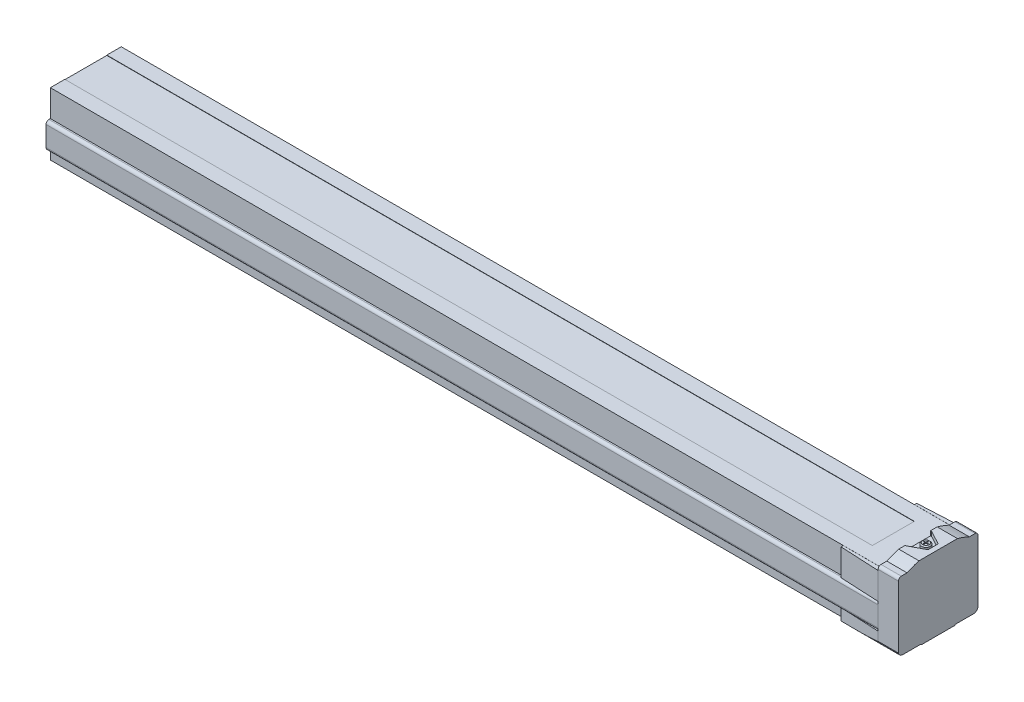
from build123d import *

# Parameters (mm, degrees)
BOSS_EXTRUDE1_DEPTH          = 930
SKETCH2_W                    = 204.786284779
SKETCH2_H                    = 168.647528641
CUT_EXTRUDE1_DEPTH           = 909.5
SKETCH3_W                    = 400
SKETCH3_H                    = 200
CUT_EXTRUDE2_DEPTH           = 930
BOSS_EXTRUDE2_DEPTH          = 127.35
CUT_REVOLVE1_ANGLE           = 75
CUT_REVOLVE1_OTHER_WAY_ANGLE = 75
CUT_EXTRUDE4_DEPTH           = 20
CUT_EXTRUDE5_DEPTH           = 1
CUT_EXTRUDE6_DEPTH           = 20
CUT_EXTRUDE6_DEPTH_BACK      = 20
CUT_EXTRUDE7_DEPTH           = 6
BOSS_EXTRUDE8_DEPTH          = 21.2
CUT_EXTRUDE9_DEPTH           = 30
CUT_EXTRUDE9_DEPTH_BACK      = 30
CUT_EXTRUDE10_DEPTH          = 2
CUT_EXTRUDE10_DEPTH_BACK     = 2
SKETCH14_R                   = 3.25
BOSS_EXTRUDE3_DEPTH          = 20
SKETCH15_R                   = 3.25
BOSS_EXTRUDE4_DEPTH          = 20
BOSS_EXTRUDE5_DEPTH          = 8.56
SKETCH17_W                   = 235.37802201
SKETCH17_H                   = 195.027503951
CUT_EXTRUDE14_DEPTH          = 40
BOSS_EXTRUDE6_DEPTH          = 18.5
BOSS_EXTRUDE7_DEPTH          = 8.56
CUT_EXTRUDE17_START          = -50
SKETCH20_W                   = 235.37802201
SKETCH20_H                   = 195.027503951
CUT_EXTRUDE17_DEPTH          = 50
CUT_EXTRUDE18_DEPTH          = 3
SKETCH23_W                   = 742
SKETCH23_H                   = 29
CUT_EXTRUDE19_DEPTH          = 0.2
CUT_EXTRUDE20_DEPTH          = 25
CUT_EXTRUDE20_DEPTH_BACK     = 25
CUT_EXTRUDE21_DEPTH          = 16
CUT_EXTRUDE22_DEPTH          = 16
CUT_EXTRUDE23_DEPTH          = 34
CUT_EXTRUDE24_DEPTH          = 34
CUT_EXTRUDE25_DEPTH          = 16
CUT_EXTRUDE26_DEPTH          = 16
CUT_EXTRUDE27_DEPTH          = 12.5
CUT_EXTRUDE28_DEPTH          = 12.5
CUT_EXTRUDE_1_DEPTH          = 341
CUT_EXTRUDE_1_DEPTH_BACK     = 341
SKETCH_2_W                   = 173.292997311
SKETCH_2_H                   = 116.860407409


with BuildPart() as part:
    # Sketch1 → Boss-Extrude1 (new body)
    with BuildSketch(Plane(origin=(0, 0, 0), x_dir=(0, 0, -1), z_dir=(1, 0, 0))):
        with BuildLine():
            Line((-28.5, 46), (-28.5, 2.971392601))
            Line((-28.5, 2.971392601), (-27.5, 2.971392601))
            Line((-27.5, 2.971392601), (-27.328427125, 2.5))
            ThreePointArc((-27.328427125, 2.5), (-26.232050808, 1.050510257), (-24.5, 0.5))
            Line((-24.5, 0.5), (-12, 0.5))
            Line((-12, 0.5), (-11.5, 0))
            Line((-11.5, 0), (11.5, 0))
            Line((11.5, 0), (12, 0.5))
            Line((12, 0.5), (24.5, 0.5))
            ThreePointArc((24.5, 0.5), (26.232050808, 1.050510257), (27.328427125, 2.5))
            Line((27.328427125, 2.5), (27.5, 2.971392601))
            Line((27.5, 2.971392601), (28.5, 2.971392601))
            Line((28.5, 2.971392601), (28.5, 46))
            Line((28.5, 46), (27.5, 46))
            ThreePointArc((27.5, 46), (26.914213562, 47.414213562), (25.5, 48))
            Line((25.5, 48), (21.524012172, 48))
            ThreePointArc((21.524012172, 48), (17.477101448, 49.71603425), (13.295111884, 51.07))
            Line((13.295111884, 51.07), (-13.295111884, 51.07))
            ThreePointArc((-13.295111884, 51.07), (-17.477101448, 49.71603425), (-21.524012172, 48))
            Line((-21.524012172, 48), (-25.5, 48))
            ThreePointArc((-25.5, 48), (-26.914213562, 47.414213562), (-27.5, 46))
            Line((-27.5, 46), (-28.5, 46))
        make_face()
    extrude(amount=BOSS_EXTRUDE1_DEPTH)

    # Sketch2 → Cut-Extrude1 (cut)
    with BuildSketch(Plane(origin=(916, 0, 0), x_dir=(0, 0, -1), z_dir=(1, 0, 0))):
        with Locations((9.532349098, 15.424002622)):
            Rectangle(SKETCH2_W, SKETCH2_H)
        with BuildLine():
            Line((-27.5, 24.8), (-27.5, 11))
            ThreePointArc((-27.5, 11), (-26.914213562, 9.585786438), (-25.5, 9))
            Line((-25.5, 9), (-24.5, 9))
            Line((-24.5, 9), (-24.5, 2))
            Line((-24.5, 2), (-22.5, 0))
            Line((-22.5, 0), (22.5, 0))
            Line((22.5, 0), (24.5, 2))
            Line((24.5, 2), (24.5, 9))
            Line((24.5, 9), (25.5, 9))
            ThreePointArc((25.5, 9), (26.914213562, 9.585786438), (27.5, 11))
            Line((27.5, 11), (27.5, 24.8))
            ThreePointArc((27.5, 24.8), (26.914213562, 26.214213562), (25.5, 26.8))
            Line((25.5, 26.8), (24.5, 26.8))
            Line((24.5, 26.8), (24.5, 45.3))
            Line((24.5, 45.3), (-24.5, 45.3))
            Line((-24.5, 45.3), (-24.5, 26.8))
            Line((-24.5, 26.8), (-25.5, 26.8))
            ThreePointArc((-25.5, 26.8), (-26.914213562, 26.214213562), (-27.5, 24.8))
        make_face(mode=Mode.SUBTRACT)
    extrude(amount=-CUT_EXTRUDE1_DEPTH, mode=Mode.SUBTRACT)

    # Sketch3 → Cut-Extrude2 (cut)
    with BuildSketch(Plane(origin=(0, 0, 0), x_dir=(0, 0, -1), z_dir=(1, 0, 0))):
        Rectangle(SKETCH3_W, SKETCH3_H)
        with BuildLine():
            Line((-27.5, 46), (-27.5, 2.971392601))
            Line((-27.5, 2.971392601), (-27.328427125, 2.5))
            ThreePointArc((-27.328427125, 2.5), (-26.232050808, 1.050510257), (-24.5, 0.5))
            Line((-24.5, 0.5), (-12, 0.5))
            Line((-12, 0.5), (-11.5, 0))
            Line((-11.5, 0), (11.5, 0))
            Line((11.5, 0), (12, 0.5))
            Line((12, 0.5), (24.5, 0.5))
            ThreePointArc((24.5, 0.5), (26.232050808, 1.050510257), (27.328427125, 2.5))
            Line((27.328427125, 2.5), (27.5, 2.971392601))
            Line((27.5, 2.971392601), (27.5, 46))
            ThreePointArc((27.5, 46), (26.914213562, 47.414213562), (25.5, 48))
            Line((25.5, 48), (21.524012172, 48))
            ThreePointArc((21.524012172, 48), (17.477101448, 49.71603425), (13.295111884, 51.07))
            Line((13.295111884, 51.07), (-13.295111884, 51.07))
            ThreePointArc((-13.295111884, 51.07), (-17.477101448, 49.71603425), (-21.524012172, 48))
            Line((-21.524012172, 48), (-25.5, 48))
            ThreePointArc((-25.5, 48), (-26.914213562, 47.414213562), (-27.5, 46))
        make_face(mode=Mode.SUBTRACT)
    extrude(amount=CUT_EXTRUDE2_DEPTH, mode=Mode.SUBTRACT)

    # Sketch4 → Boss-Extrude2 (add)
    with BuildSketch(Plane(origin=(0, 0, 0), x_dir=(0, 0, -1), z_dir=(1, 0, 0))):
        with BuildLine():
            Line((-24.5, 30), (24.5, 30))
            Line((24.5, 30), (24.5, 45.3))
            Line((24.5, 45.3), (24.45, 45.3))
            Line((24.45, 45.3), (24.5, 45.35))
            Line((24.5, 45.35), (24.5, 48))
            Line((24.5, 48), (24, 48))
            Line((24, 48), (22.285663539, 52.710100717))
            ThreePointArc((22.285663539, 52.710100717), (20.455082617, 55.095760221), (17.587200435, 56))
            Line((17.587200435, 56), (-17.084187431, 56))
            ThreePointArc((-17.084187431, 56), (-19.770685472, 55.216957229), (-21.615726366, 53.113091309))
            Line((-21.615726366, 53.113091309), (-24, 48))
            Line((-24, 48), (-24.5, 48))
            Line((-24.5, 48), (-24.5, 45.35))
            Line((-24.5, 45.35), (-24.45, 45.3))
            Line((-24.45, 45.3), (-24.5, 45.3))
            Line((-24.5, 45.3), (-24.5, 30))
        make_face()
    extrude(amount=BOSS_EXTRUDE2_DEPTH)

    # Sketch5 → Cut-Revolve1 (revolve, cut)
    with BuildSketch(Plane.XY):
        with BuildLine():
            Line((97.35, 71.971261171), (150, 71.971261171))
            Line((150, 71.971261171), (150, 45.3))
            Line((150, 45.3), (127.35, 45.3))
            Line((127.35, 45.3), (127.35, 45.79))
            ThreePointArc((127.35, 45.79), (127.234272347, 46.460460828), (126.900482278, 47.053330799))
            Line((126.900482278, 47.053330799), (120.296542673, 55.158326997))
            ThreePointArc((120.296542673, 55.158326997), (118.566072869, 56.516172881), (116.420336979, 57))
            Line((116.420336979, 57), (97.35, 57))
            Line((97.35, 57), (97.35, 71.971261171))
        make_face()
    revolve(axis=Axis((97.35, 57, 0), (0, -1, 0)), revolution_arc=CUT_REVOLVE1_ANGLE, mode=Mode.SUBTRACT)

    # Sketch5 → Cut-Revolve1 other way (revolve, cut)
    with BuildSketch(Plane.XY):
        with BuildLine():
            Line((97.35, 71.971261171), (150, 71.971261171))
            Line((150, 71.971261171), (150, 45.3))
            Line((150, 45.3), (127.35, 45.3))
            Line((127.35, 45.3), (127.35, 45.79))
            ThreePointArc((127.35, 45.79), (127.234272347, 46.460460828), (126.900482278, 47.053330799))
            Line((126.900482278, 47.053330799), (120.296542673, 55.158326997))
            ThreePointArc((120.296542673, 55.158326997), (118.566072869, 56.516172881), (116.420336979, 57))
            Line((116.420336979, 57), (97.35, 57))
            Line((97.35, 57), (97.35, 71.971261171))
        make_face()
    revolve(axis=Axis((97.35, 57, 0), (0, 1, 0)), revolution_arc=CUT_REVOLVE1_OTHER_WAY_ANGLE, mode=Mode.SUBTRACT)

    # Sketch6 → Cut-Extrude4 (cut)
    with BuildSketch(Plane(origin=(0, 48, 0), x_dir=(-1, 0, 0), z_dir=(0, 1, 0))):
        Polygon((-916, 8.7), (-916.72022238, 8.7), (-926.5, 3.5), (-926.5, -3.5), (-916.72022238, -8.7), (-916, -8.7), align=None)
    extrude(amount=CUT_EXTRUDE4_DEPTH, mode=Mode.SUBTRACT)

    # Sketch7 → Revolve1 (revolve)
    with BuildSketch(Plane.XY):
        Polygon((921.5, 48), (918.5, 48), (918.5, 50.292893219), (919.207106781, 51), (921.5, 51), align=None)
    revolve(axis=Axis((921.5, 51, 0), (0, -1, 0)))

    # Sketch8 → Cut-Extrude5 (cut)
    with BuildSketch(Plane(origin=(0, 51, 0), x_dir=(-1, 0, 0), z_dir=(0, 1, 0))):
        with BuildLine():
            Line((-923.071623365, -0.3), (-921.8, -0.3))
            Line((-921.8, -0.3), (-921.8, -1.571623365))
            ThreePointArc((-921.8, -1.571623365), (-921.5, -1.6), (-921.2, -1.571623365))
            Line((-921.2, -1.571623365), (-921.2, -0.3))
            Line((-921.2, -0.3), (-919.928376635, -0.3))
            ThreePointArc((-919.928376635, -0.3), (-919.9, 0), (-919.928376635, 0.3))
            Line((-919.928376635, 0.3), (-921.2, 0.3))
            Line((-921.2, 0.3), (-921.2, 1.571623365))
            ThreePointArc((-921.2, 1.571623365), (-921.5, 1.6), (-921.8, 1.571623365))
            Line((-921.8, 1.571623365), (-921.8, 0.3))
            Line((-921.8, 0.3), (-923.071623365, 0.3))
            ThreePointArc((-923.071623365, 0.3), (-923.1, 0), (-923.071623365, -0.3))
        make_face()
    extrude(amount=-CUT_EXTRUDE5_DEPTH, mode=Mode.SUBTRACT)

    # Sketch9 → Cut-Extrude6 (cut, two sides: drawn at the far end of the back side and taken through both)
    with BuildSketch(Plane.XY.offset(-CUT_EXTRUDE6_DEPTH_BACK)):
        Polygon((-50, 0.5), (-50, 0), (79, 0), (78.5, 0.5), align=None)
    extrude(amount=CUT_EXTRUDE6_DEPTH + CUT_EXTRUDE6_DEPTH_BACK, mode=Mode.SUBTRACT)

    # Sketch10 → Cut-Extrude7 (cut)
    with BuildSketch(Plane(origin=(0, 0, 0), x_dir=(-1, 0, 0), z_dir=(0, 1, 0))):
        with BuildLine():
            Line((-625.5, 2), (-627.5, 2))
            ThreePointArc((-627.5, 2), (-629.5, 0), (-627.5, -2))
            Line((-627.5, -2), (-625.5, -2))
            ThreePointArc((-625.5, -2), (-623.5, 0), (-625.5, 2))
        make_face()
    extrude(amount=CUT_EXTRUDE7_DEPTH, mode=Mode.SUBTRACT)

    # Sketch11 → Boss-Extrude8 (add)
    with BuildSketch(Plane(origin=(0, 26.8, 0), x_dir=(-1, 0, 0), z_dir=(0, 1, 0))):
        Polygon((0, 27.5), (-6, 27.5), (-34, 26.1), (-34, -26.1), (-6, -27.5), (0, -27.5), align=None)
    extrude(amount=BOSS_EXTRUDE8_DEPTH)

    # Sketch12 → Cut-Extrude9 (cut, two sides: drawn at the far end of the back side and taken through both)
    with BuildSketch(Plane.XY.offset(-CUT_EXTRUDE9_DEPTH_BACK)):
        with BuildLine():
            Line((-20, -15), (15, -15))
            Line((15, -15), (15, 0))
            Line((15, 0), (5.587775501, 0))
            ThreePointArc((5.587775501, 0), (2.209824463, 1.313613316), (0.60680201, 4.564221286))
            Line((0.60680201, 4.564221286), (0, 11.5))
            Line((0, 11.5), (0, 40.45))
            Line((0, 40.45), (2.189670922, 52.868240888))
            ThreePointArc((2.189670922, 52.868240888), (3.899771638, 55.830222216), (7.113709687, 57))
            Line((7.113709687, 57), (15, 57))
            Line((15, 57), (15, 60))
            Line((15, 60), (-20, 60))
            Line((-20, 60), (-20, -15))
        make_face()
    extrude(amount=CUT_EXTRUDE9_DEPTH + CUT_EXTRUDE9_DEPTH_BACK, mode=Mode.SUBTRACT)

    # Sketch13 → Cut-Extrude10 (cut, two sides: drawn at the far end of the back side and taken through both)
    with BuildSketch(Plane(origin=(0, 0, 0), x_dir=(0, 0, -1), z_dir=(1, 0, 0)).offset(-CUT_EXTRUDE10_DEPTH_BACK)):
        with BuildLine():
            Line((-10, 46.95), (-10, 42.95))
            ThreePointArc((-10, 42.95), (-8.535533906, 39.414466094), (-5, 37.95))
            Line((-5, 37.95), (5, 37.95))
            ThreePointArc((5, 37.95), (8.535533906, 39.414466094), (10, 42.95))
            Line((10, 42.95), (10, 46.95))
            ThreePointArc((10, 46.95), (9.707106781, 47.657106781), (9, 47.95))
            Line((9, 47.95), (-9, 47.95))
            ThreePointArc((-9, 47.95), (-9.707106781, 47.657106781), (-10, 46.95))
        make_face()
    extrude(amount=CUT_EXTRUDE10_DEPTH + CUT_EXTRUDE10_DEPTH_BACK, mode=Mode.SUBTRACT)

    # Sketch14 → Boss-Extrude3 (add)
    with BuildSketch(Plane(origin=(2, 0, 0), x_dir=(0, 0, -1), z_dir=(1, 0, 0))):
        with Locations((-3.5, 43.7)):
            Circle(SKETCH14_R)
    extrude(amount=-BOSS_EXTRUDE3_DEPTH)

    # Sketch15 → Boss-Extrude4 (add)
    with BuildSketch(Plane(origin=(2, 0, 0), x_dir=(0, 0, -1), z_dir=(1, 0, 0))):
        with Locations((3.5, 43.7)):
            Circle(SKETCH15_R)
    extrude(amount=-BOSS_EXTRUDE4_DEPTH)

    # Sketch16 → Boss-Extrude5 (add)
    with BuildSketch(Plane(origin=(0, 9, 0), x_dir=(-1, 0, 0), z_dir=(0, 1, 0))):
        Polygon((0, 27.5), (-6, 27.5), (-34, 26.1), (-34, -26.1), (-6, -27.5), (0, -27.5), align=None)
    extrude(amount=-BOSS_EXTRUDE5_DEPTH)

    # Sketch17 → Cut-Extrude14 (cut)
    with BuildSketch(Plane(origin=(0, 0, 0), x_dir=(0, 0, -1), z_dir=(1, 0, 0))):
        with Locations((8.296344577, 18.152881027)):
            Rectangle(SKETCH17_W, SKETCH17_H)
        with BuildLine():
            Line((-27.5, 46), (-27.5, 2.971392601))
            Line((-27.5, 2.971392601), (-27.328427125, 2.5))
            ThreePointArc((-27.328427125, 2.5), (-26.232050808, 1.050510257), (-24.5, 0.5))
            Line((-24.5, 0.5), (24.5, 0.5))
            ThreePointArc((24.5, 0.5), (26.232050808, 1.050510257), (27.328427125, 2.5))
            Line((27.328427125, 2.5), (27.5, 2.971392601))
            Line((27.5, 2.971392601), (27.5, 46))
            ThreePointArc((27.5, 46), (26.914213562, 47.414213562), (25.5, 48))
            Line((25.5, 48), (24, 48))
            Line((24, 48), (24, 65))
            Line((24, 65), (-24, 65))
            Line((-24, 65), (-24, 48))
            Line((-24, 48), (-25.5, 48))
            ThreePointArc((-25.5, 48), (-26.914213562, 47.414213562), (-27.5, 46))
        make_face(mode=Mode.SUBTRACT)
    extrude(amount=CUT_EXTRUDE14_DEPTH, mode=Mode.SUBTRACT)

    # Sketch18 → Boss-Extrude6 (add)
    with BuildSketch(Plane(origin=(0, 26.8, 0), x_dir=(-1, 0, 0), z_dir=(0, 1, 0))):
        Polygon((-889, 26.1), (-917, 27.5), (-923, 27.5), (-923, -27.5), (-917, -27.5), (-889, -26.1), align=None)
    extrude(amount=BOSS_EXTRUDE6_DEPTH)

    # Sketch19 → Boss-Extrude7 (add)
    with BuildSketch(Plane(origin=(0, 9, 0), x_dir=(-1, 0, 0), z_dir=(0, 1, 0))):
        Polygon((-889, 26.1), (-917, 27.5), (-930, 27.5), (-930, -27.5), (-917, -27.5), (-889, -26.1), align=None)
    extrude(amount=-BOSS_EXTRUDE7_DEPTH)

    # Sketch20 → Cut-Extrude17 (cut)
    with BuildSketch(Plane(origin=(930, 0, 0), x_dir=(0, 0, -1), z_dir=(1, 0, 0)).offset(CUT_EXTRUDE17_START)):
        with Locations((8.296344577, 18.152881027)):
            Rectangle(SKETCH20_W, SKETCH20_H)
        with BuildLine():
            Line((-27.5, 46), (-27.5, 2.971392601))
            Line((-27.5, 2.971392601), (-27.328427125, 2.5))
            ThreePointArc((-27.328427125, 2.5), (-26.232050808, 1.050510257), (-24.5, 0.5))
            Line((-24.5, 0.5), (-12, 0.5))
            Line((-12, 0.5), (-11.5, 0))
            Line((-11.5, 0), (11.5, 0))
            Line((11.5, 0), (12, 0.5))
            Line((12, 0.5), (24.5, 0.5))
            ThreePointArc((24.5, 0.5), (26.232050808, 1.050510257), (27.328427125, 2.5))
            Line((27.328427125, 2.5), (27.5, 2.971392601))
            Line((27.5, 2.971392601), (27.5, 46))
            ThreePointArc((27.5, 46), (26.914213562, 47.414213562), (25.5, 48))
            Line((25.5, 48), (24, 48))
            Line((24, 48), (24, 65))
            Line((24, 65), (-24, 65))
            Line((-24, 65), (-24, 48))
            Line((-24, 48), (-25.5, 48))
            ThreePointArc((-25.5, 48), (-26.914213562, 47.414213562), (-27.5, 46))
        make_face(mode=Mode.SUBTRACT)
    extrude(amount=CUT_EXTRUDE17_DEPTH, mode=Mode.SUBTRACT)

    # Sketch21 → Cut-Revolve2 (revolve, cut)
    with BuildSketch(Plane.XY):
        Polygon((111, 60.83306822), (116, 60.83306822), (116, 55.5), (115.7, 55.8), (111, 55.8), align=None)
    revolve(axis=Axis((111, 55.8, 0), (0, 1, 0)), mode=Mode.SUBTRACT)

    # Sketch22 → Cut-Extrude18 (cut)
    with BuildSketch(Plane(origin=(0, 55.8, 0), x_dir=(-1, 0, 0), z_dir=(0, 1, 0))):
        with BuildLine():
            Line((-108.041960108, 0.5), (-110.5, 0.5))
            Line((-110.5, 0.5), (-110.5, 2.958039892))
            ThreePointArc((-110.5, 2.958039892), (-111, 3), (-111.5, 2.958039892))
            Line((-111.5, 2.958039892), (-111.5, 0.5))
            Line((-111.5, 0.5), (-113.958039892, 0.5))
            ThreePointArc((-113.958039892, 0.5), (-114, 0), (-113.958039892, -0.5))
            Line((-113.958039892, -0.5), (-111.5, -0.5))
            Line((-111.5, -0.5), (-111.5, -2.958039892))
            ThreePointArc((-111.5, -2.958039892), (-111, -3), (-110.5, -2.958039892))
            Line((-110.5, -2.958039892), (-110.5, -0.5))
            Line((-110.5, -0.5), (-108.041960108, -0.5))
            ThreePointArc((-108.041960108, -0.5), (-108, 0), (-108.041960108, 0.5))
        make_face()
    extrude(amount=-CUT_EXTRUDE18_DEPTH, mode=Mode.SUBTRACT)

    # Sketch23 → Cut-Extrude19 (cut)
    with BuildSketch(Plane(origin=(0, 45.3, 0), x_dir=(-1, 0, 0), z_dir=(0, 1, 0))):
        with Locations((-528, 0)):
            Rectangle(SKETCH23_W, SKETCH23_H)
    extrude(amount=-CUT_EXTRUDE19_DEPTH, mode=Mode.SUBTRACT)

    # Sketch24 → Cut-Revolve3 (revolve, cut)
    with BuildSketch(Plane.XY):
        Polygon((126.5, 0), (124.5, 0), (124.5, 6), (126.5, 7.154700538), align=None)
    revolve(axis=Axis((126.5, 7.154700538, 0), (0, -1, 0)), mode=Mode.SUBTRACT)

    # Sketch25 → Cut-Revolve4 (revolve, cut)
    with BuildSketch(Plane(origin=(101.5, 0, 0), x_dir=(0, 0, -1), z_dir=(1, 0, 0))):
        Polygon((0, 11.019415637), (2.4585, 9.6), (2.4585, 0.5415), (3, 0), (0, 0), align=None)
    revolve(axis=Axis((101.5, 0, 0), (0, 1, 0)), mode=Mode.SUBTRACT)

    # Sketch26 → Cut-Revolve5 (revolve, cut)
    with BuildSketch(Plane(origin=(901.5, 0, 0), x_dir=(0, 0, -1), z_dir=(1, 0, 0))):
        Polygon((0, 11.019415637), (2.4585, 9.6), (2.4585, 0.5415), (3, 0), (0, 0), align=None)
    revolve(axis=Axis((901.5, 0, 0), (0, 1, 0)), mode=Mode.SUBTRACT)

    # Sketch27 → Cut-Revolve6 (revolve, cut)
    with BuildSketch(Plane(origin=(851.5, 0, 0), x_dir=(0, 0, -1), z_dir=(1, 0, 0))):
        Polygon((0, 11.019415637), (2.4585, 9.6), (2.4585, 0.5415), (3, 0), (0, 0), align=None)
    revolve(axis=Axis((851.5, 0, 0), (0, 1, 0)), mode=Mode.SUBTRACT)

    # Sketch28 → Cut-Revolve7 (revolve, cut)
    with BuildSketch(Plane(origin=(801.5, 0, 0), x_dir=(0, 0, -1), z_dir=(1, 0, 0))):
        Polygon((0, 11.019415637), (2.4585, 9.6), (2.4585, 0.5415), (3, 0), (0, 0), align=None)
    revolve(axis=Axis((801.5, 0, 0), (0, 1, 0)), mode=Mode.SUBTRACT)

    # Sketch29 → Cut-Revolve8 (revolve, cut)
    with BuildSketch(Plane(origin=(751.5, 0, 0), x_dir=(0, 0, -1), z_dir=(1, 0, 0))):
        Polygon((0, 11.019415637), (2.4585, 9.6), (2.4585, 0.5415), (3, 0), (0, 0), align=None)
    revolve(axis=Axis((751.5, 0, 0), (0, 1, 0)), mode=Mode.SUBTRACT)

    # Sketch30 → Cut-Revolve9 (revolve, cut)
    with BuildSketch(Plane(origin=(701.5, 0, 0), x_dir=(0, 0, -1), z_dir=(1, 0, 0))):
        Polygon((0, 11.019415637), (2.4585, 9.6), (2.4585, 0.5415), (3, 0), (0, 0), align=None)
    revolve(axis=Axis((701.5, 0, 0), (0, 1, 0)), mode=Mode.SUBTRACT)

    # Sketch31 → Cut-Revolve10 (revolve, cut)
    with BuildSketch(Plane(origin=(651.5, 0, 0), x_dir=(0, 0, -1), z_dir=(1, 0, 0))):
        Polygon((0, 11.019415637), (2.4585, 9.6), (2.4585, 0.5415), (3, 0), (0, 0), align=None)
    revolve(axis=Axis((651.5, 0, 0), (0, 1, 0)), mode=Mode.SUBTRACT)

    # Sketch32 → Cut-Revolve11 (revolve, cut)
    with BuildSketch(Plane(origin=(601.5, 0, 0), x_dir=(0, 0, -1), z_dir=(1, 0, 0))):
        Polygon((0, 11.019415637), (2.4585, 9.6), (2.4585, 0.5415), (3, 0), (0, 0), align=None)
    revolve(axis=Axis((601.5, 0, 0), (0, 1, 0)), mode=Mode.SUBTRACT)

    # Sketch33 → Cut-Revolve12 (revolve, cut)
    with BuildSketch(Plane(origin=(551.5, 0, 0), x_dir=(0, 0, -1), z_dir=(1, 0, 0))):
        Polygon((0, 11.019415637), (2.4585, 9.6), (2.4585, 0.5415), (3, 0), (0, 0), align=None)
    revolve(axis=Axis((551.5, 0, 0), (0, 1, 0)), mode=Mode.SUBTRACT)

    # Sketch34 → Cut-Revolve13 (revolve, cut)
    with BuildSketch(Plane(origin=(501.5, 0, 0), x_dir=(0, 0, -1), z_dir=(1, 0, 0))):
        Polygon((0, 11.019415637), (2.4585, 9.6), (2.4585, 0.5415), (3, 0), (0, 0), align=None)
    revolve(axis=Axis((501.5, 0, 0), (0, 1, 0)), mode=Mode.SUBTRACT)

    # Sketch35 → Cut-Revolve14 (revolve, cut)
    with BuildSketch(Plane(origin=(451.5, 0, 0), x_dir=(0, 0, -1), z_dir=(1, 0, 0))):
        Polygon((0, 11.019415637), (2.4585, 9.6), (2.4585, 0.5415), (3, 0), (0, 0), align=None)
    revolve(axis=Axis((451.5, 0, 0), (0, 1, 0)), mode=Mode.SUBTRACT)

    # Sketch36 → Cut-Revolve15 (revolve, cut)
    with BuildSketch(Plane(origin=(401.5, 0, 0), x_dir=(0, 0, -1), z_dir=(1, 0, 0))):
        Polygon((0, 11.019415637), (2.4585, 9.6), (2.4585, 0.5415), (3, 0), (0, 0), align=None)
    revolve(axis=Axis((401.5, 0, 0), (0, 1, 0)), mode=Mode.SUBTRACT)

    # Sketch37 → Cut-Revolve16 (revolve, cut)
    with BuildSketch(Plane(origin=(351.5, 0, 0), x_dir=(0, 0, -1), z_dir=(1, 0, 0))):
        Polygon((0, 11.019415637), (2.4585, 9.6), (2.4585, 0.5415), (3, 0), (0, 0), align=None)
    revolve(axis=Axis((351.5, 0, 0), (0, 1, 0)), mode=Mode.SUBTRACT)

    # Sketch38 → Cut-Revolve17 (revolve, cut)
    with BuildSketch(Plane(origin=(301.5, 0, 0), x_dir=(0, 0, -1), z_dir=(1, 0, 0))):
        Polygon((0, 11.019415637), (2.4585, 9.6), (2.4585, 0.5415), (3, 0), (0, 0), align=None)
    revolve(axis=Axis((301.5, 0, 0), (0, 1, 0)), mode=Mode.SUBTRACT)

    # Sketch39 → Cut-Revolve18 (revolve, cut)
    with BuildSketch(Plane(origin=(251.5, 0, 0), x_dir=(0, 0, -1), z_dir=(1, 0, 0))):
        Polygon((0, 11.019415637), (2.4585, 9.6), (2.4585, 0.5415), (3, 0), (0, 0), align=None)
    revolve(axis=Axis((251.5, 0, 0), (0, 1, 0)), mode=Mode.SUBTRACT)

    # Sketch40 → Cut-Revolve19 (revolve, cut)
    with BuildSketch(Plane(origin=(201.5, 0, 0), x_dir=(0, 0, -1), z_dir=(1, 0, 0))):
        Polygon((0, 11.019415637), (2.4585, 9.6), (2.4585, 0.5415), (3, 0), (0, 0), align=None)
    revolve(axis=Axis((201.5, 0, 0), (0, 1, 0)), mode=Mode.SUBTRACT)

    # Sketch41 → Cut-Revolve20 (revolve, cut)
    with BuildSketch(Plane(origin=(151.5, 0, 0), x_dir=(0, 0, -1), z_dir=(1, 0, 0))):
        Polygon((0, 11.019415637), (2.4585, 9.6), (2.4585, 0.5415), (3, 0), (0, 0), align=None)
    revolve(axis=Axis((151.5, 0, 0), (0, 1, 0)), mode=Mode.SUBTRACT)

    # Sketch42 → Cut-Extrude20 (cut, two sides: drawn at the far end of the back side and taken through both)
    with BuildSketch(Plane.XY.offset(-CUT_EXTRUDE20_DEPTH_BACK)):
        Polygon((34, 0.5), (34.05, 0.5), (34, 0.55), align=None)
    extrude(amount=CUT_EXTRUDE20_DEPTH + CUT_EXTRUDE20_DEPTH_BACK, mode=Mode.SUBTRACT)

    # Sketch43 → Cut-Extrude21 (cut)
    with BuildSketch(Plane(origin=(0, 26.8, 0), x_dir=(-1, 0, 0), z_dir=(0, 1, 0))):
        Polygon((-6.5, 27.5), (-6.55, 27.5), (-6.5, 27.45), align=None)
    extrude(amount=-CUT_EXTRUDE21_DEPTH, mode=Mode.SUBTRACT)

    # Sketch44 → Cut-Extrude22 (cut)
    with BuildSketch(Plane(origin=(0, 26.8, 0), x_dir=(-1, 0, 0), z_dir=(0, 1, 0))):
        Polygon((-6.5, -27.5), (-6.5, -27.45), (-6.55, -27.5), align=None)
    extrude(amount=-CUT_EXTRUDE22_DEPTH, mode=Mode.SUBTRACT)

    # Sketch45 → Cut-Extrude23 (cut)
    with BuildSketch(Plane(origin=(916, 0, 0), x_dir=(0, 0, -1), z_dir=(1, 0, 0))):
        Polygon((-24.558, 45.3), (-24.5, 45.25), (-24.5, 45.3), align=None)
    extrude(amount=-CUT_EXTRUDE23_DEPTH, mode=Mode.SUBTRACT)

    # Sketch46 → Cut-Extrude24 (cut)
    with BuildSketch(Plane(origin=(916, 0, 0), x_dir=(0, 0, -1), z_dir=(1, 0, 0))):
        Polygon((24.5, 45.25), (24.558, 45.3), (24.5, 45.3), align=None)
    extrude(amount=-CUT_EXTRUDE24_DEPTH, mode=Mode.SUBTRACT)

    # Sketch47 → Cut-Extrude25 (cut)
    with BuildSketch(Plane(origin=(0, 26.8, 0), x_dir=(-1, 0, 0), z_dir=(0, 1, 0))):
        Polygon((-915.95, 27.5), (-916, 27.5), (-916, 27.45), align=None)
    extrude(amount=-CUT_EXTRUDE25_DEPTH, mode=Mode.SUBTRACT)

    # Sketch48 → Cut-Extrude26 (cut)
    with BuildSketch(Plane(origin=(0, 26.8, 0), x_dir=(-1, 0, 0), z_dir=(0, 1, 0))):
        Polygon((-915.95, -27.5), (-916, -27.45), (-916, -27.5), align=None)
    extrude(amount=-CUT_EXTRUDE26_DEPTH, mode=Mode.SUBTRACT)

    # Sketch49 → Cut-Extrude27 (cut)
    with BuildSketch(Plane.XY.offset(24.5)):
        Polygon((888.95, 0.5), (889, 0.5), (889, 0.55), align=None)
    extrude(amount=-CUT_EXTRUDE27_DEPTH, mode=Mode.SUBTRACT)

    # Sketch50 → Cut-Extrude28 (cut)
    with BuildSketch(Plane.XY.offset(-24.5)):
        Polygon((888.95, 0.5), (889, 0.5), (889, 0.55), align=None)
    extrude(amount=CUT_EXTRUDE28_DEPTH, mode=Mode.SUBTRACT)

    # Эскиз2 → Вырез-Вытянуть1 (cut, two sides: drawn at the far end of the back side and taken through both)
    with BuildSketch(Plane.ZY.offset(-CUT_EXTRUDE_1_DEPTH_BACK)):
        with Locations((5.233568924, 21.12160272)):
            Rectangle(SKETCH_2_W, SKETCH_2_H)
    extrude(amount=CUT_EXTRUDE_1_DEPTH + CUT_EXTRUDE_1_DEPTH_BACK, mode=Mode.SUBTRACT)


solid = part.part
